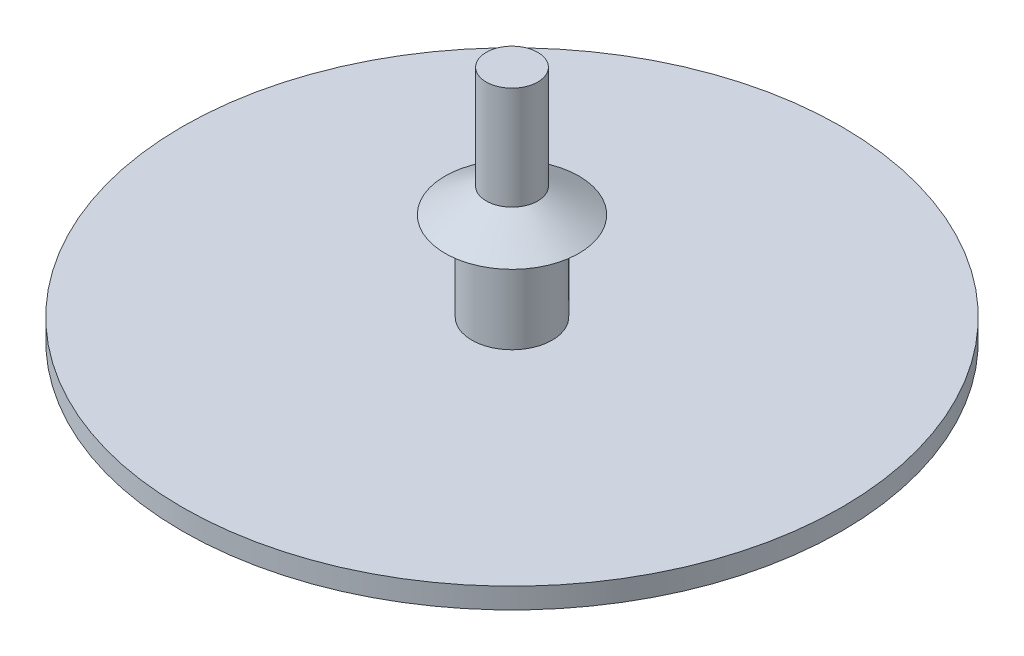
from build123d import *


with BuildPart() as part:
    # Sketch1 → Revolve1 (revolve)
    with BuildSketch(Plane.XY):
        Polygon((1.95, 0.5), (1.95, 4.8), (3.25, 4.8), (1.25, 6), (1.25, 11), (0, 11), (0, -0.5), (16, -0.5), (16, 0.5), align=None)
    revolve(axis=Axis((0, 0, 0), (0, 1, 0)))


solid = part.part
